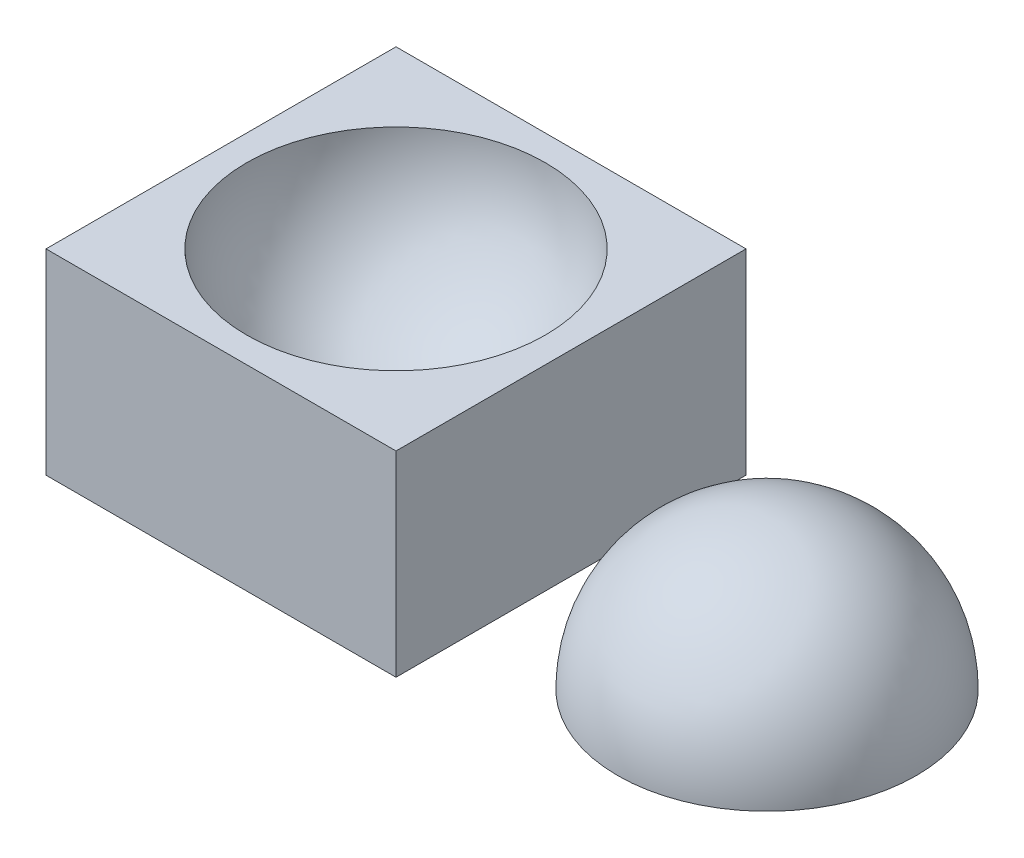
from build123d import *

# Parameters (mm, degrees)
SKETCH2_W           = 75
SKETCH2_H           = 75
BOSS_EXTRUDE2_DEPTH = 42


with BuildPart() as part:
    # Sketch2 → Boss-Extrude2 (new body)
    with BuildSketch(Plane(origin=(0, 0, 0), x_dir=(1, 0, 0), z_dir=(0, 1, 0))):
        Rectangle(SKETCH2_W, SKETCH2_H)
    extrude(amount=BOSS_EXTRUDE2_DEPTH)

    # Sketch4 → Cut-Revolve2 (revolve, cut)
    with BuildSketch(Plane(origin=(0, 0, 0), x_dir=(0, 0, -1), z_dir=(1, 0, 0))):
        with BuildLine():
            Line((0, 42), (0, 10))
            ThreePointArc((0, 10), (22.627416998, 19.372583002), (32, 42))
            Line((32, 42), (0, 42))
        make_face()
    revolve(axis=Axis((0, 42, 0), (0, -1, 0)), mode=Mode.SUBTRACT)


with BuildPart() as body_2:
    # Sketch6 → Revolve1 (revolve)
    with BuildSketch(Plane.XY):
        with BuildLine():
            Line((47.5, 0), (79.5, 0))
            Line((79.5, 0), (79.5, 32))
            ThreePointArc((79.5, 32), (56.872583002, 22.627416998), (47.5, 0))
        make_face()
    revolve(axis=Axis((79.5, 0, 0), (0, 1, 0)))


solid = Compound([part.part, body_2.part])
